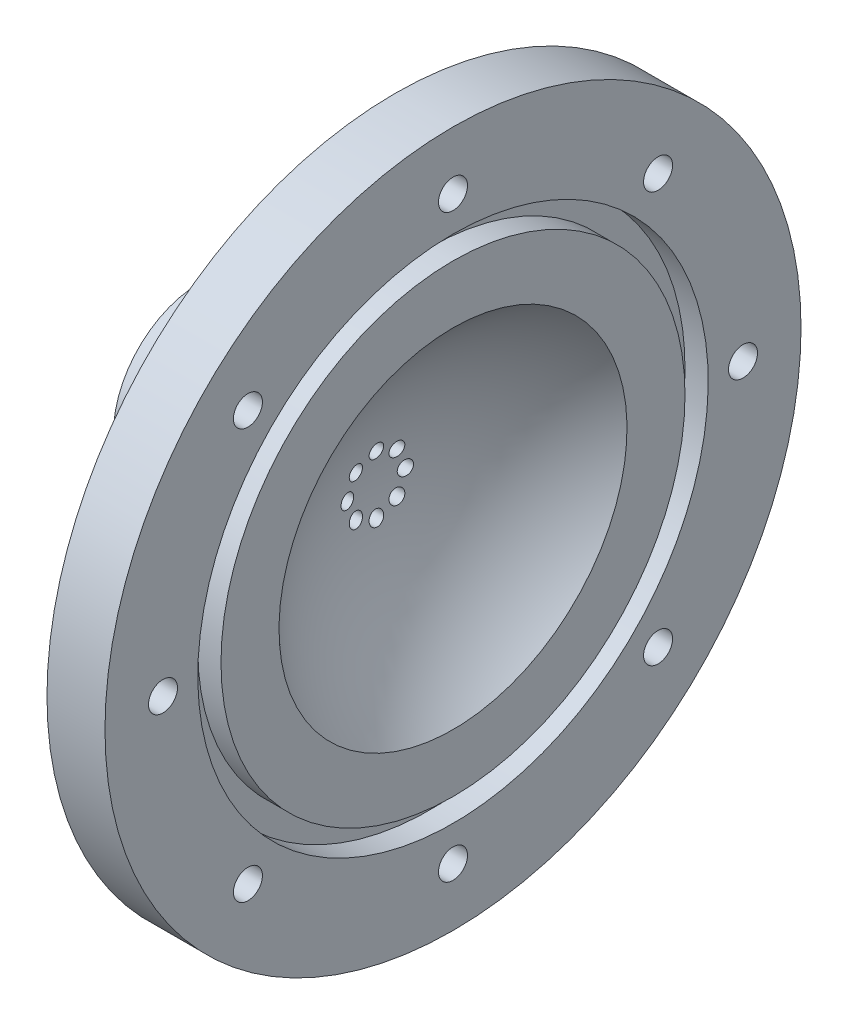
from build123d import *

# Parameters (mm, degrees)
F_1_16_0_0625_DIAMETER_HOLE1_D = 1.5875
CIRPATTERN2_COUNT              = 8
F_1_8_0_125_DIAMETER_HOLE1_D   = 3.175
CIRPATTERN1_COUNT              = 8


with BuildPart() as part:
    # Sketch1 → Revolve1 (revolve)
    with BuildSketch(Plane.XY):
        with BuildLine():
            Line((0, 38.1), (0, 27.94))
            Line((0, 27.94), (-2.54, 27.94))
            Line((-2.54, 27.94), (-2.54, 25.4))
            Line((-2.54, 25.4), (0, 25.4))
            Line((0, 25.4), (0, 19.05))
            ThreePointArc((0, 19.05), (-6.35, 10.450520825), (-8.599479175, 0))
            Line((-8.599479175, 0), (-27.649479175, 0))
            Line((-27.649479175, 0), (-27.649479175, 9.525))
            Line((-27.649479175, 9.525), (-13.48704882, 9.525))
            ThreePointArc((-13.48704882, 9.525), (-10.606359164, 16.028893575), (-6.35, 21.72822785))
            Line((-6.35, 21.72822785), (-6.35, 38.1))
            Line((-6.35, 38.1), (0, 38.1))
        make_face()
    revolve(axis=Axis((-8.599479175, 0, 0), (-1, 0, 0)))

    # Sketch5 → 1_4 NPT Tapped Hole1 (revolve, cut)
    with BuildSketch(Plane(origin=(-27.649479175, 0, 0), x_dir=(0, 0, 1), z_dir=(0, 1, 0))):
        Polygon((0, 0), (0, 16.042347279), (5.5626, 12.7), (5.5626, 9.906), (5.943685794, 9.906), (6.2402847, 0), align=None)
    revolve(axis=Axis((-33.999479175, 0, 0), (1, 0, 0)), mode=Mode.SUBTRACT)

    # 1_16 _0.0625_ Diameter Hole1 (through all)
    with Locations(Plane(origin=(0, 0, 0), x_dir=(0, 0, -1), z_dir=(1, 0, 0))):
        with Locations((0, 3.175)):
            f_1_16_0_0625_diameter_hole1 = Hole(F_1_16_0_0625_DIAMETER_HOLE1_D / 2)

    # CirPattern2: 1_16 _0.0625_ Diameter Hole1 ×8 about axis
    cirpattern2_axis = Axis((-98.515, 0, 0), (1, 0, 0))
    for i in range(1, CIRPATTERN2_COUNT):
        add(f_1_16_0_0625_diameter_hole1.rotate(cirpattern2_axis, i * 360 / CIRPATTERN2_COUNT), mode=Mode.SUBTRACT)

    # 1_8 _0.125_ Diameter Hole1 (through all)
    with Locations(Plane(origin=(0, 0, 0), x_dir=(0, 0, -1), z_dir=(1, 0, 0))):
        with Locations((0, 31.75)):
            f_1_8_0_125_diameter_hole1 = Hole(F_1_8_0_125_DIAMETER_HOLE1_D / 2)

    # CirPattern1: 1_8 _0.125_ Diameter Hole1 ×8 about axis
    cirpattern1_axis = Axis((-98.515, 0, 0), (1, 0, 0))
    for i in range(1, CIRPATTERN1_COUNT):
        add(f_1_8_0_125_diameter_hole1.rotate(cirpattern1_axis, i * 360 / CIRPATTERN1_COUNT), mode=Mode.SUBTRACT)


solid = part.part
